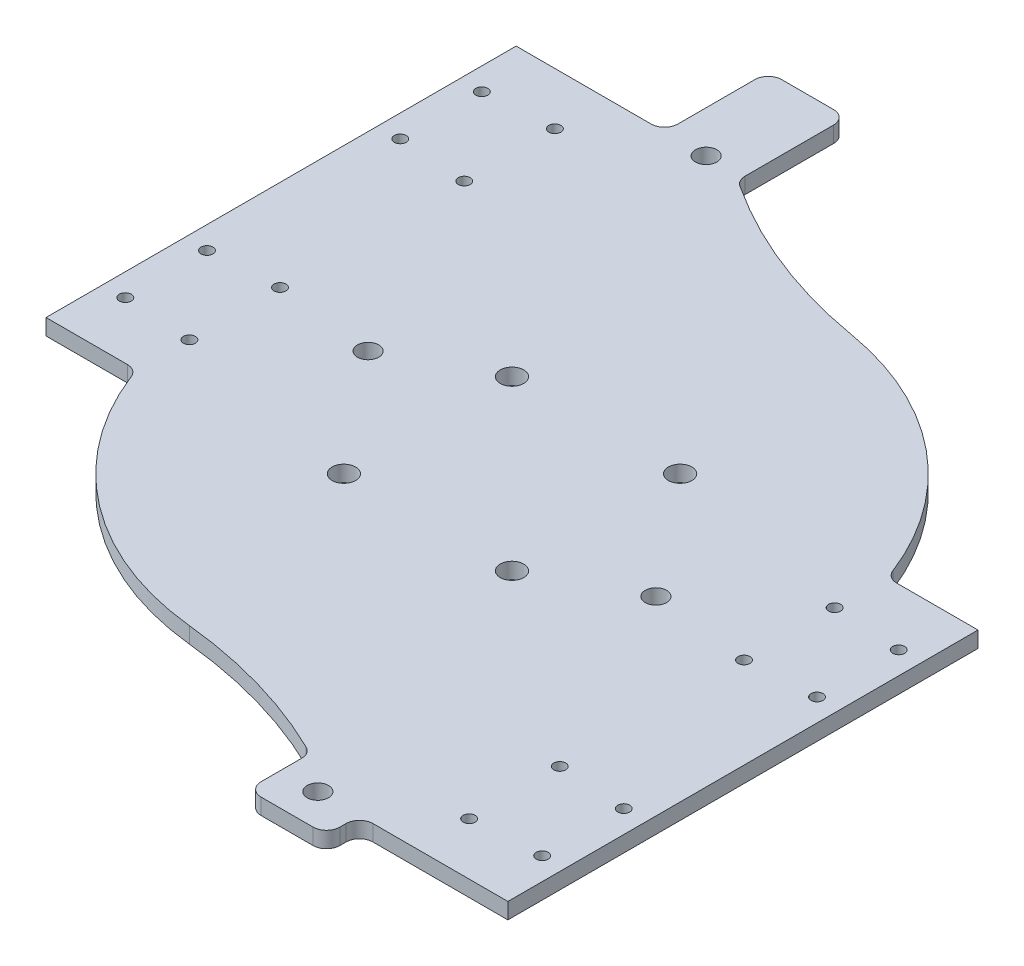
from build123d import *

# Parameters (mm, degrees)
SKETCH1_R           = 3.5
SKETCH1_R_2         = 3.175
SKETCH1_R_3         = 1.778
BOSS_EXTRUDE1_DEPTH = 4.7625


with BuildPart() as part:
    # Sketch1 → Boss-Extrude1 (new body)
    with BuildSketch(Plane(origin=(0, 0, 0), x_dir=(1, 0, 0), z_dir=(0, 1, 0))):
        with BuildLine():
            Line((-82.138222173, -9.295950869), (-57.965959984, -9.295950869))
            ThreePointArc((-57.965959984, -9.295950869), (-55.705057174, -9.996205654), (-54.23575837, -11.851791627))
            ThreePointArc((-54.23575837, -11.851791627), (-25.688309848, -49.851999329), (18.508323348, -67.334282266))
            ThreePointArc((18.508323348, -67.334282266), (43.48483848, -72.142696572), (67.225777827, -81.270399198))
            ThreePointArc((67.225777827, -81.270399198), (68.831606216, -82.733374325), (69.400777827, -84.829805749))
            Line((69.400777827, -84.829805749), (69.400777827, -96.829805749))
            ThreePointArc((69.400777827, -96.829805749), (70.572350702, -99.658232874), (73.400777827, -100.829805749))
            Line((73.400777827, -100.829805749), (88.810777827, -100.829805749))
            ThreePointArc((88.810777827, -100.829805749), (91.639204952, -99.658232874), (92.810777827, -96.829805749))
            Line((92.810777827, -96.829805749), (92.810777827, -95.010813721))
            ThreePointArc((92.810777827, -95.010813721), (93.982350702, -92.182386597), (96.810777827, -91.010813721))
            Line((96.810777827, -91.010813721), (136.939777827, -91.010813721))
            Line((136.939777827, -91.010813721), (136.939777827, 48.804049131))
            Line((136.939777827, 48.804049131), (112.767515638, 48.804049131))
            ThreePointArc((112.767515638, 48.804049131), (110.506612828, 49.504303916), (109.037314024, 51.359889889))
            ThreePointArc((109.037314024, 51.359889889), (82.815823158, 87.522965038), (42.165907723, 106.041036281))
            ThreePointArc((42.165907723, 106.041036281), (13.766481711, 113.962861296), (-12.424222173, 127.502792592))
            ThreePointArc((-12.424222173, 127.502792592), (-14.009500528, 128.976393784), (-14.59507652, 131.060070509))
            Line((-14.59507652, 131.060070509), (-14.59507652, 157.379549131))
            ThreePointArc((-14.59507652, 157.379549131), (-15.766649396, 160.207976256), (-18.59507652, 161.379549131))
            Line((-18.59507652, 161.379549131), (-34.009222173, 161.379549131))
            ThreePointArc((-34.009222173, 161.379549131), (-36.837649298, 160.207976256), (-38.009222173, 157.379549131))
            Line((-38.009222173, 157.379549131), (-38.009222173, 134.518911983))
            ThreePointArc((-38.009222173, 134.518911983), (-39.180795048, 131.690484859), (-42.009222173, 130.518911983))
            Line((-42.009222173, 130.518911983), (-82.138222173, 130.518911983))
            Line((-82.138222173, 130.518911983), (-82.138222173, -9.295950869))
        make_face()
        with Locations((52.400777827, 44.754049131)):
            Circle(SKETCH1_R, mode=Mode.SUBTRACT)
        with Locations((52.400777827, -5.245950869)):
            Circle(SKETCH1_R, mode=Mode.SUBTRACT)
        with Locations((80.400777827, 9.550885679)):
            Circle(SKETCH1_R_2, mode=Mode.SUBTRACT)
        with Locations((109.880393645, 33.224433313)):
            Circle(SKETCH1_R_3, mode=Mode.SUBTRACT)
        with Locations((109.880393645, 6.283664949)):
            Circle(SKETCH1_R_3, mode=Mode.SUBTRACT)
        with Locations((109.880393645, -48.53042954)):
            Circle(SKETCH1_R_3, mode=Mode.SUBTRACT)
        with Locations((109.880393645, -75.471197903)):
            Circle(SKETCH1_R_3, mode=Mode.SUBTRACT)
        with Locations((130.26557504, -49.865610934)):
            Circle(SKETCH1_R_3, mode=Mode.SUBTRACT)
        with Locations((130.26557504, -74.136016508)):
            Circle(SKETCH1_R_3, mode=Mode.SUBTRACT)
        with Locations((130.26557504, 31.889251918)):
            Circle(SKETCH1_R_3, mode=Mode.SUBTRACT)
        with Locations((130.26557504, 7.618846344)):
            Circle(SKETCH1_R_3, mode=Mode.SUBTRACT)
        with Locations((80.400777827, -90.985264901)):
            Circle(SKETCH1_R_2, mode=Mode.SUBTRACT)
        with Locations((2.400777827, -5.245950869)):
            Circle(SKETCH1_R, mode=Mode.SUBTRACT)
        with Locations((2.400777827, 44.754049131)):
            Circle(SKETCH1_R, mode=Mode.SUBTRACT)
        with Locations((-25.599222173, 29.957212583)):
            Circle(SKETCH1_R_2, mode=Mode.SUBTRACT)
        with Locations((-55.078837991, 6.283664949)):
            Circle(SKETCH1_R_3, mode=Mode.SUBTRACT)
        with Locations((-55.078837991, 33.224433313)):
            Circle(SKETCH1_R_3, mode=Mode.SUBTRACT)
        with Locations((-55.078837991, 88.038527802)):
            Circle(SKETCH1_R_3, mode=Mode.SUBTRACT)
        with Locations((-55.078837991, 114.979296165)):
            Circle(SKETCH1_R_3, mode=Mode.SUBTRACT)
        with Locations((-75.464019386, 89.373709197)):
            Circle(SKETCH1_R_3, mode=Mode.SUBTRACT)
        with Locations((-75.464019386, 113.64411477)):
            Circle(SKETCH1_R_3, mode=Mode.SUBTRACT)
        with Locations((-75.464019386, 7.618846344)):
            Circle(SKETCH1_R_3, mode=Mode.SUBTRACT)
        with Locations((-75.464019386, 31.889251918)):
            Circle(SKETCH1_R_3, mode=Mode.SUBTRACT)
        with Locations((-25.599222173, 130.493363164)):
            Circle(SKETCH1_R_2, mode=Mode.SUBTRACT)
    extrude(amount=BOSS_EXTRUDE1_DEPTH)


solid = part.part
